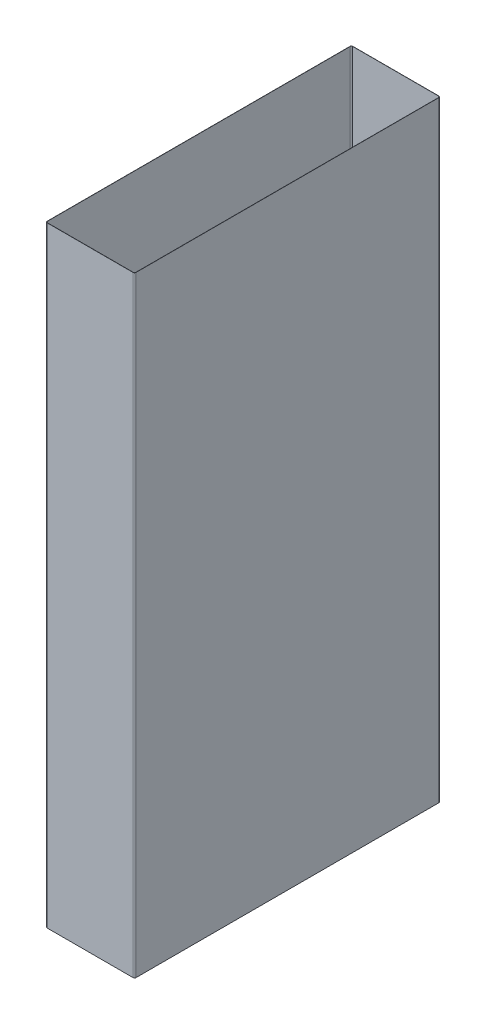
from build123d import *

# Parameters (mm, degrees)
EXTRUDE_THIN1_DEPTH = 484.8


with BuildPart() as part:
    # Sketch1 → Extrude-Thin1 (new body)
    with BuildSketch(Plane(origin=(0, 0, 0), x_dir=(1, 0, 0), z_dir=(0, 1, 0))):
        with BuildLine():
            Line((-0.15, 241.4), (-0.15, 1))
            ThreePointArc((-0.15, 1), (0.186827202, 0.186827202), (1, -0.15))
            Line((1, -0.15), (69.2, -0.15))
            ThreePointArc((69.2, -0.15), (70.013172798, 0.186827202), (70.35, 1))
            Line((70.35, 1), (70.35, 241.4))
            ThreePointArc((70.35, 241.4), (70.013172798, 242.213172798), (69.2, 242.55))
            Line((69.2, 242.55), (1, 242.55))
            ThreePointArc((1, 242.55), (0.186827202, 242.213172798), (-0.15, 241.4))
        make_face()
        with BuildLine():
            Line((0, 241.4), (0, 1))
            ThreePointArc((0, 1), (0.292893219, 0.292893219), (1, 0))
            Line((1, 0), (69.2, 0))
            ThreePointArc((69.2, 0), (69.907106781, 0.292893219), (70.2, 1))
            Line((70.2, 1), (70.2, 241.4))
            ThreePointArc((70.2, 241.4), (69.907106781, 242.107106781), (69.2, 242.4))
            Line((69.2, 242.4), (1, 242.4))
            ThreePointArc((1, 242.4), (0.292893219, 242.107106781), (0, 241.4))
        make_face(mode=Mode.SUBTRACT)
    extrude(amount=EXTRUDE_THIN1_DEPTH)


solid = part.part
